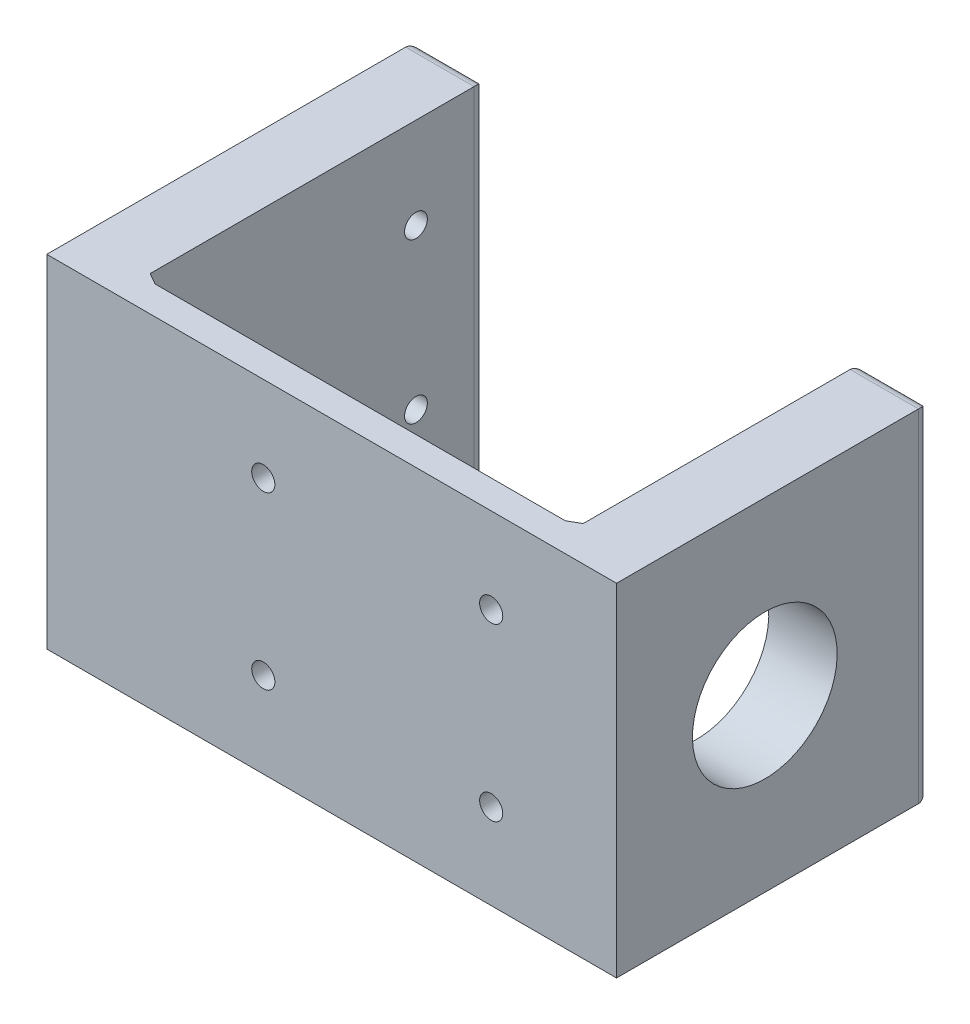
from build123d import *

# Parameters (mm, degrees)
SKETCH2_W                        = 127
SKETCH2_H                        = 76.2
BOSS_EXTRUDE1_DEPTH              = 6.35
F_13_64_0_20313_DIAMETER_HOLE1_D = 5.159502
SKETCH5_W                        = 15.24
SKETCH5_H                        = 76.2
BOSS_EXTRUDE2_DEPTH              = 63.5
CHAMFER1_SIZE                    = 2.54
CHAMFER1_SIZE2                   = 1.466469684
FILLET3_R                        = 2.54
SKETCH9_W                        = 15.24
SKETCH9_H                        = 76.2
BOSS_EXTRUDE3_DEPTH              = 76.2
CHAMFER5_SIZE                    = 2.54
CHAMFER5_SIZE2                   = 1.466469684
FILLET5_R                        = 2.54
CUT_EXTRUDE1_REACH               = 129
SKETCH17_R                       = 2.54
CUT_EXTRUDE2_REACH               = 129
SKETCH18_R                       = 16.129


with BuildPart() as part:
    # Sketch2 → Boss-Extrude1 (new body)
    with BuildSketch(Plane.XY):
        with Locations((-63.5, 38.1)):
            Rectangle(SKETCH2_W, SKETCH2_H)
    extrude(amount=BOSS_EXTRUDE1_DEPTH)

    # 13/64 (0.20313) Diameter Hole1 (through all)
    with Locations(Plane.XY.offset(6.35)):
        with Locations((-78.74, 57.15), (-78.74, 19.05), (-27.94, 57.15), (-27.94, 19.05)):
            Hole(F_13_64_0_20313_DIAMETER_HOLE1_D / 2)

    # Sketch5 → Boss-Extrude2 (add)
    with BuildSketch(Plane(origin=(0, 0, 0), x_dir=(-1, 0, 0), z_dir=(0, 0, -1))):
        with Locations((7.62, 38.1)):
            Rectangle(SKETCH5_W, SKETCH5_H)
    extrude(amount=BOSS_EXTRUDE2_DEPTH)

    # Chamfer1
    chamfer1_edges = [part.edges().sort_by_distance(p)[0] for p in [
        (-15.24, 38.1, 0),
    ]]
    chamfer1_side = [part.faces().sort_by_distance(p)[0] for p in [
        (-71.296336335, 38.1, 0),
    ]]
    chamfer(chamfer1_edges, length=CHAMFER1_SIZE, length2=CHAMFER1_SIZE2, reference=chamfer1_side[0])

    # Fillet3
    fillet3_edges = [part.edges().sort_by_distance(p)[0] for p in [
        (-15.24, 38.1, -63.5),
        (-7.62, 76.2, -63.5),
        (0, 38.1, -63.5),
        (-7.62, 0, -63.5),
    ]]
    fillet(fillet3_edges, radius=FILLET3_R)

    # Sketch9 → Boss-Extrude3 (add)
    with BuildSketch(Plane(origin=(0, 0, 0), x_dir=(-1, 0, 0), z_dir=(0, 0, -1))):
        with Locations((119.38, 38.1)):
            Rectangle(SKETCH9_W, SKETCH9_H)
    extrude(amount=BOSS_EXTRUDE3_DEPTH)

    # Chamfer5
    chamfer5_edges = [part.edges().sort_by_distance(p)[0] for p in [
        (-111.76, 38.1, 0),
    ]]
    chamfer5_side = [part.faces().sort_by_distance(p)[0] for p in [
        (-64.905058797, 38.1, 0),
    ]]
    chamfer(chamfer5_edges, length=CHAMFER5_SIZE, length2=CHAMFER5_SIZE2, reference=chamfer5_side[0])

    # Fillet5
    fillet5_edges = [part.edges().sort_by_distance(p)[0] for p in [
        (-127, 38.1, -76.2),
        (-119.38, 76.2, -76.2),
        (-111.76, 38.1, -76.2),
        (-119.38, 0, -76.2),
    ]]
    fillet(fillet5_edges, radius=FILLET5_R)

    # Sketch17 → Cut-Extrude1 (cut, up to next)
    with BuildSketch(Plane.ZY.offset(127), mode=Mode.PRIVATE) as cut_extrude1_sk1:
        with Locations((-12.7, 20.32)):
            Circle(SKETCH17_R)
    cut_extrude1_tool1 = extrude(cut_extrude1_sk1.sketch, amount=-CUT_EXTRUDE1_REACH, mode=Mode.PRIVATE) & part.part
    add(cut_extrude1_tool1.solids().sort_by_distance((-127, 20.32, -12.7))[0], mode=Mode.SUBTRACT)
    # Sketch17 → Cut-Extrude1 (cut, up to next)
    with BuildSketch(Plane.ZY.offset(127), mode=Mode.PRIVATE) as cut_extrude1_sk2:
        with Locations((-12.7, 55.88)):
            Circle(SKETCH17_R)
    cut_extrude1_tool2 = extrude(cut_extrude1_sk2.sketch, amount=-CUT_EXTRUDE1_REACH, mode=Mode.PRIVATE) & part.part
    add(cut_extrude1_tool2.solids().sort_by_distance((-127, 55.88, -12.7))[0], mode=Mode.SUBTRACT)
    # Sketch17 → Cut-Extrude1 (cut, up to next)
    with BuildSketch(Plane.ZY.offset(127), mode=Mode.PRIVATE) as cut_extrude1_sk3:
        with Locations((-60.7, 20.32)):
            Circle(SKETCH17_R)
    cut_extrude1_tool3 = extrude(cut_extrude1_sk3.sketch, amount=-CUT_EXTRUDE1_REACH, mode=Mode.PRIVATE) & part.part
    add(cut_extrude1_tool3.solids().sort_by_distance((-127, 20.32, -60.7))[0], mode=Mode.SUBTRACT)
    # Sketch17 → Cut-Extrude1 (cut, up to next)
    with BuildSketch(Plane.ZY.offset(127), mode=Mode.PRIVATE) as cut_extrude1_sk4:
        with Locations((-60.7, 55.88)):
            Circle(SKETCH17_R)
    cut_extrude1_tool4 = extrude(cut_extrude1_sk4.sketch, amount=-CUT_EXTRUDE1_REACH, mode=Mode.PRIVATE) & part.part
    add(cut_extrude1_tool4.solids().sort_by_distance((-127, 55.88, -60.7))[0], mode=Mode.SUBTRACT)

    # Sketch18 → Cut-Extrude2 (cut, up to next)
    with BuildSketch(Plane(origin=(0, 0, 0), x_dir=(0, 0, -1), z_dir=(1, 0, 0)), mode=Mode.PRIVATE) as cut_extrude2_sk1:
        with Locations((26.7, 38.02)):
            Circle(SKETCH18_R)
    cut_extrude2_tool1 = extrude(cut_extrude2_sk1.sketch, amount=-CUT_EXTRUDE2_REACH, mode=Mode.PRIVATE) & part.part
    add(cut_extrude2_tool1.solids().sort_by_distance((0, 38.02, -26.7))[0], mode=Mode.SUBTRACT)


solid = part.part
